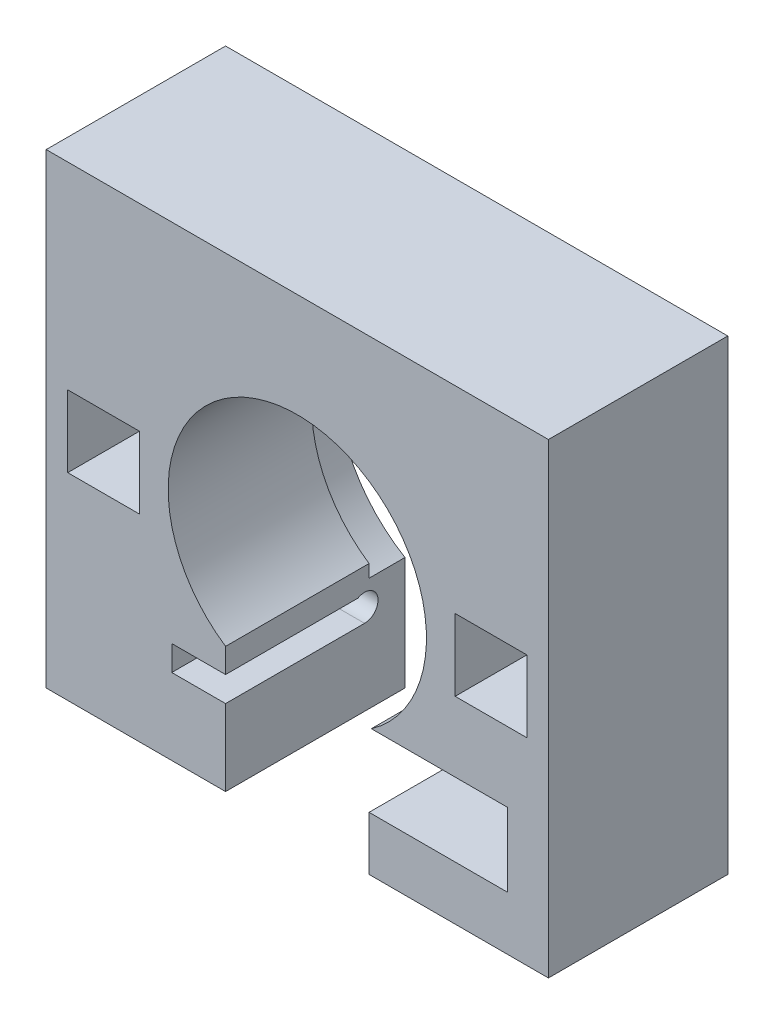
from build123d import *

# Parameters (mm, degrees)
SKETCH_1_W          = 140
SKETCH_1_H          = 130
SKETCH_1_R          = 36
SKETCH_1_W_2        = 20
SKETCH_1_H_2        = 20
EXTRUDE_1_DEPTH     = 50
SKETCH_2_R          = 39
CUT_EXTRUDE_1_DEPTH = 10
CUT_EXTRUDE_2_REACH = 132
SKETCH_3_W          = 40
SKETCH_3_H          = 50
SKETCH_4_R          = 3.75
SKETCH_4_W          = 38.75
SKETCH_4_H          = 7
CUT_EXTRUDE_3_DEPTH = 15
SKETCH_6_W          = 9.65
SKETCH_6_H          = 20.5
CUT_EXTRUDE_4_DEPTH = 51
SKETCH_7_W          = 29
SKETCH_7_H          = 20.5
CUT_EXTRUDE_5_DEPTH = 41


with BuildPart() as part:
    # 草圖1 → 填料-伸長1 (new body)
    with BuildSketch(Plane.XY):
        with Locations((8.56146046, -8.054151625)):
            Rectangle(SKETCH_1_W, SKETCH_1_H)
        with Locations((8.56146046, -8.054151625)):
            Circle(SKETCH_1_R, mode=Mode.SUBTRACT)
        with Locations((-45.43853954, -8.054151625)):
            Rectangle(SKETCH_1_W_2, SKETCH_1_H_2, mode=Mode.SUBTRACT)
        with Locations((62.56146046, -8.054151625)):
            Rectangle(SKETCH_1_W_2, SKETCH_1_H_2, mode=Mode.SUBTRACT)
    extrude(amount=EXTRUDE_1_DEPTH)

    # 草圖2 → 除料-伸長1 (cut)
    with BuildSketch(Plane(origin=(0, 0, 0), x_dir=(-1, 0, 0), z_dir=(0, 0, -1))):
        with Locations((-8.56146046, -8.054151625)):
            Circle(SKETCH_2_R)
    extrude(amount=-CUT_EXTRUDE_1_DEPTH, mode=Mode.SUBTRACT)

    # 草圖3 → 除料-伸長2 (cut, up to next)
    with BuildSketch(Plane.XZ.offset(73.054151625), mode=Mode.PRIVATE) as cut_extrude_2_sk1:
        with Locations((8.56146046, 25)):
            Rectangle(SKETCH_3_W, SKETCH_3_H)
    cut_extrude_2_tool1 = extrude(cut_extrude_2_sk1.sketch, amount=-CUT_EXTRUDE_2_REACH, mode=Mode.PRIVATE) & part.part
    add(cut_extrude_2_tool1.solids().sort_by_distance((8.56146, -73.054152, 25))[0], mode=Mode.SUBTRACT)

    # 草圖4 → 除料-伸長3 (cut)
    with BuildSketch(Plane(origin=(-11.43853954, 0, 0), x_dir=(0, 0, -1), z_dir=(1, 0, 0))):
        with Locations((-11.25, -48.054151625)):
            Circle(SKETCH_4_R)
        with Locations((-30.625, -48.304151625)):
            Rectangle(SKETCH_4_W, SKETCH_4_H)
    extrude(amount=-CUT_EXTRUDE_3_DEPTH, mode=Mode.SUBTRACT)

    # 草圖6 → 除料-伸長4 (cut, through all)
    with BuildSketch(Plane.XY.offset(50)):
        with Locations((33.38646046, -47.804151625)):
            Rectangle(SKETCH_6_W, SKETCH_6_H)
    extrude(amount=-CUT_EXTRUDE_4_DEPTH, mode=Mode.SUBTRACT)

    # 草圖7 → 除料-伸長5 (cut)
    with BuildSketch(Plane.XY.offset(50)):
        with Locations((52.71146046, -47.804151625)):
            Rectangle(SKETCH_7_W, SKETCH_7_H)
    extrude(amount=-CUT_EXTRUDE_5_DEPTH, mode=Mode.SUBTRACT)


solid = part.part
